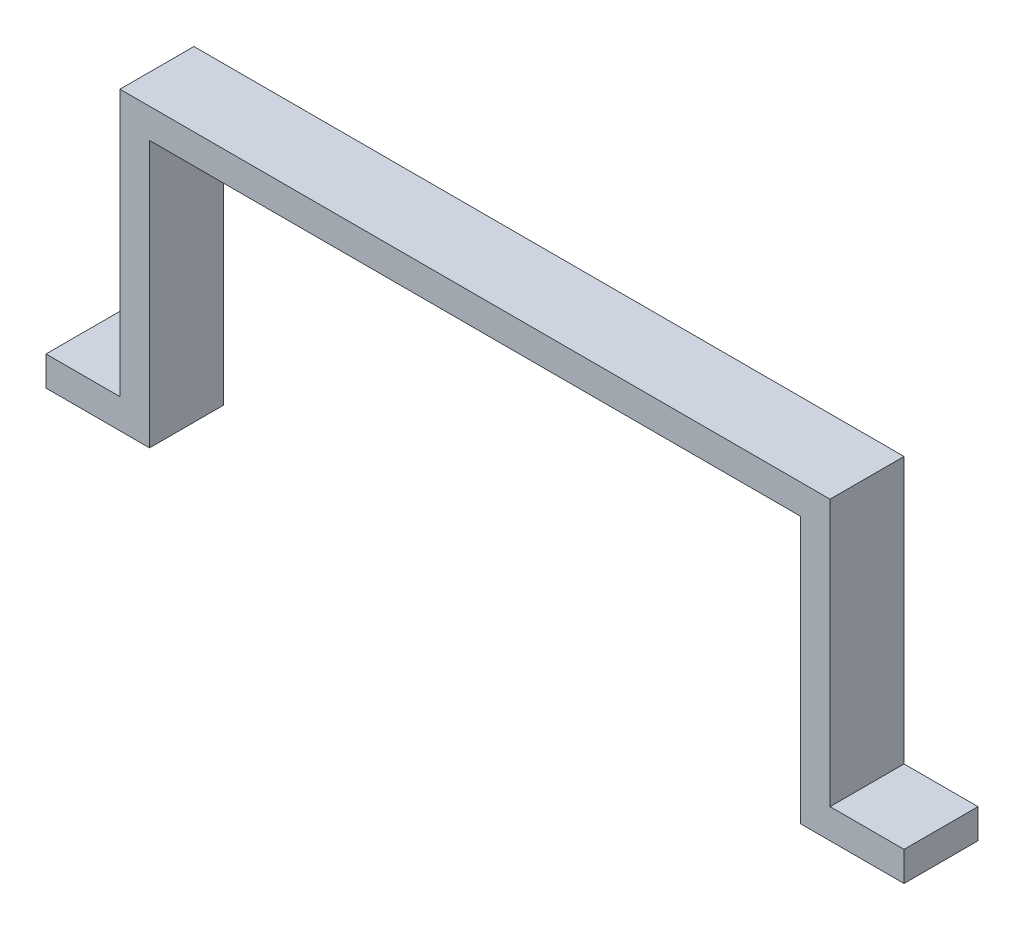
from build123d import *

# Parameters (mm, degrees)
BOSS_EXTRUDE1_DEPTH = 50


with BuildPart() as part:
    # Sketch1 → Boss-Extrude1 (new body)
    with BuildSketch(Plane.XY):
        Polygon((-290, 0), (-220, 0), (-220, 20), (-220, 180), (220, 180), (220, 20), (220, 0), (290, 0), (290, 20), (240, 20), (240, 140.360024578), (240, 200), (-240, 200), (-240, 140.360024578), (-240, 20), (-290, 20), align=None)
    extrude(amount=BOSS_EXTRUDE1_DEPTH)


solid = part.part
